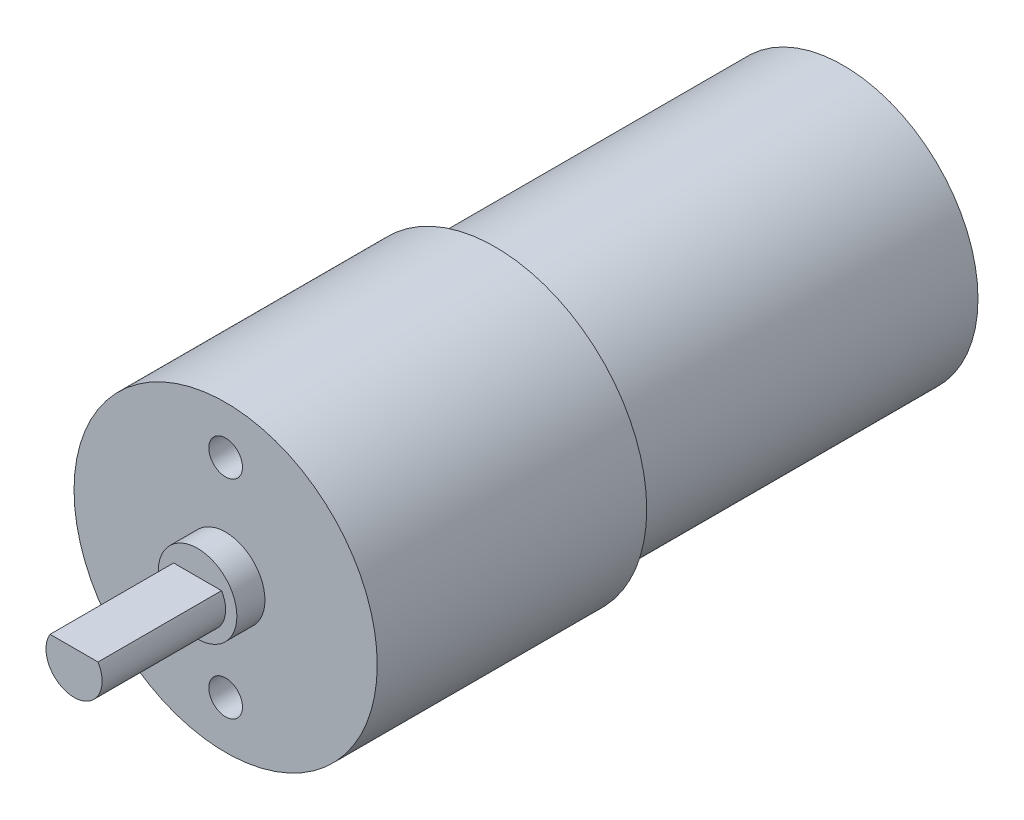
from build123d import *

# Parameters (mm, degrees)
SKETCH1_R           = 13.5
BOSS_EXTRUDE1_DEPTH = 24
BOSS_EXTRUDE2_START = -24
SKETCH1_3_R         = 12
BOSS_EXTRUDE2_DEPTH = 31
SKETCH2_R           = 3.5
BOSS_EXTRUDE3_DEPTH = 2.5
BOSS_EXTRUDE4_START = 2.5
BOSS_EXTRUDE4_DEPTH = 11
SKETCH3_R           = 1.5
CUT_EXTRUDE1_DEPTH  = 4


with BuildPart() as part:
    # Sketch1 → Boss-Extrude1 (new body)
    with BuildSketch(Plane.XY):
        Circle(SKETCH1_R)
    extrude(amount=-BOSS_EXTRUDE1_DEPTH)

    # Sketch1_3 → Boss-Extrude2 (add)
    with BuildSketch(Plane.XY.offset(BOSS_EXTRUDE2_START)):
        Circle(SKETCH1_3_R)
    extrude(amount=-BOSS_EXTRUDE2_DEPTH)

    # Sketch2 → Boss-Extrude3 (add)
    with BuildSketch(Plane.XY):
        Circle(SKETCH2_R)
    extrude(amount=BOSS_EXTRUDE3_DEPTH)

    # Sketch2_3 → Boss-Extrude4 (add)
    with BuildSketch(Plane.XY.offset(BOSS_EXTRUDE4_START)):
        with BuildLine():
            Line((2.13541565, 1.3), (-2.13541565, 1.3))
            ThreePointArc((-2.13541565, 1.3), (-0.675078097, -2.407128905), (2.5, 0))
            ThreePointArc((2.5, 0), (2.407128905, 0.675078097), (2.13541565, 1.3))
        make_face()
    extrude(amount=BOSS_EXTRUDE4_DEPTH)

    # Sketch3 → Cut-Extrude1 (cut)
    with BuildSketch(Plane.XY):
        with Locations((0, 9.25)):
            Circle(SKETCH3_R)
        with Locations((0, -9.25)):
            Circle(SKETCH3_R)
    extrude(amount=-CUT_EXTRUDE1_DEPTH, mode=Mode.SUBTRACT)


solid = part.part
